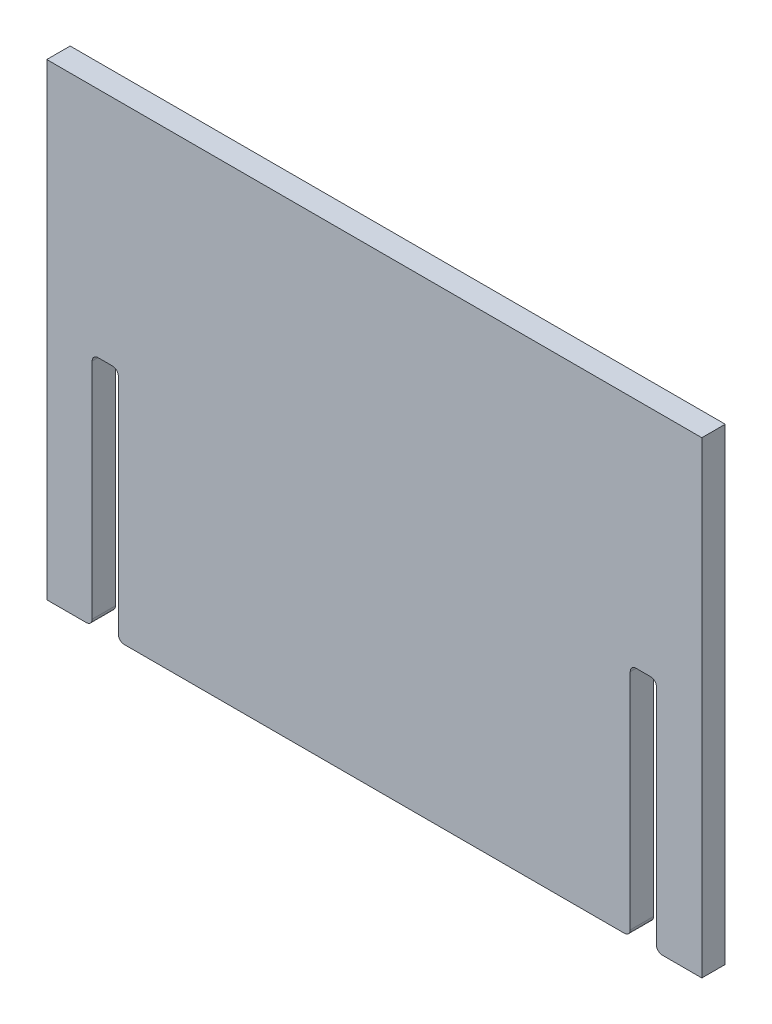
from build123d import *

# Parameters (mm, degrees)
BOSS_EXTRUDE1_DEPTH = 6.35
MOVE_FACE_SLOT_BY   = 0.762
MOVE_FACE_SLOT_2_BY = 0.762
MOVE_FACE_SLOT_3_BY = 0.762
MOVE_FACE_SLOT_4_BY = 0.762
MOVE_FACE_SLOT_5_BY = 0.762
MOVE_FACE_SLOT_6_BY = 0.762
FILLET1_R           = 3.175


with BuildPart() as part:
    # Sketch1 → Boss-Extrude1 (new, symmetric)
    with BuildSketch(Plane.XY):
        Polygon((1294.203955658, -24.179867224), (1649.803955658, -24.179867224), (1649.803955658, -278.179867224), (1624.403955658, -278.179867224), (1624.403955658, -151.179867224), (1611.703955658, -151.179867224), (1611.703955658, -278.179867224), (1332.303955658, -278.179867224), (1332.303955658, -151.179867224), (1319.603955658, -151.179867224), (1319.603955658, -278.179867224), (1294.203955658, -278.179867224), align=None)
    extrude(amount=BOSS_EXTRUDE1_DEPTH, both=True)

    # Move Face slot: a face moved inward by 0.762
    extrude(part.faces().sort_by_distance((1624.403955658, -214.679867224, 0))[0], amount=MOVE_FACE_SLOT_BY, dir=(1, 0, 0), mode=Mode.SUBTRACT)

    # Move Face slot 2: a face moved inward by 0.762
    extrude(part.faces().sort_by_distance((1618.053955658, -151.179867224, 0))[0], amount=MOVE_FACE_SLOT_2_BY, dir=(0, 1, 0), mode=Mode.SUBTRACT)

    # Move Face slot 3: a face moved inward by 0.762
    extrude(part.faces().sort_by_distance((1611.703955658, -214.679867224, 0))[0], amount=MOVE_FACE_SLOT_3_BY, dir=(-1, 0, 0), mode=Mode.SUBTRACT)

    # Move Face slot 4: a face moved inward by 0.762
    extrude(part.faces().sort_by_distance((1319.603955658, -214.679867224, 0))[0], amount=MOVE_FACE_SLOT_4_BY, dir=(-1, 0, 0), mode=Mode.SUBTRACT)

    # Move Face slot 5: a face moved inward by 0.762
    extrude(part.faces().sort_by_distance((1325.953955658, -151.179867224, 0))[0], amount=MOVE_FACE_SLOT_5_BY, dir=(0, 1, 0), mode=Mode.SUBTRACT)

    # Move Face slot 6: a face moved inward by 0.762
    extrude(part.faces().sort_by_distance((1332.303955658, -214.679867224, 0))[0], amount=MOVE_FACE_SLOT_6_BY, dir=(1, 0, 0), mode=Mode.SUBTRACT)

    # Fillet1
    fillet1_edges = [part.edges().sort_by_distance(p)[0] for p in [
        (1625.165955658, -278.179867224, 0),
        (1625.165955658, -150.417867224, 0),
        (1610.941955658, -150.417867224, 0),
        (1610.941955658, -278.179867224, 0),
        (1333.065955658, -278.179867224, 0),
        (1333.065955658, -150.417867224, 0),
        (1318.841955658, -150.417867224, 0),
        (1318.841955658, -278.179867224, 0),
    ]]
    fillet(fillet1_edges, radius=FILLET1_R)


solid = part.part
